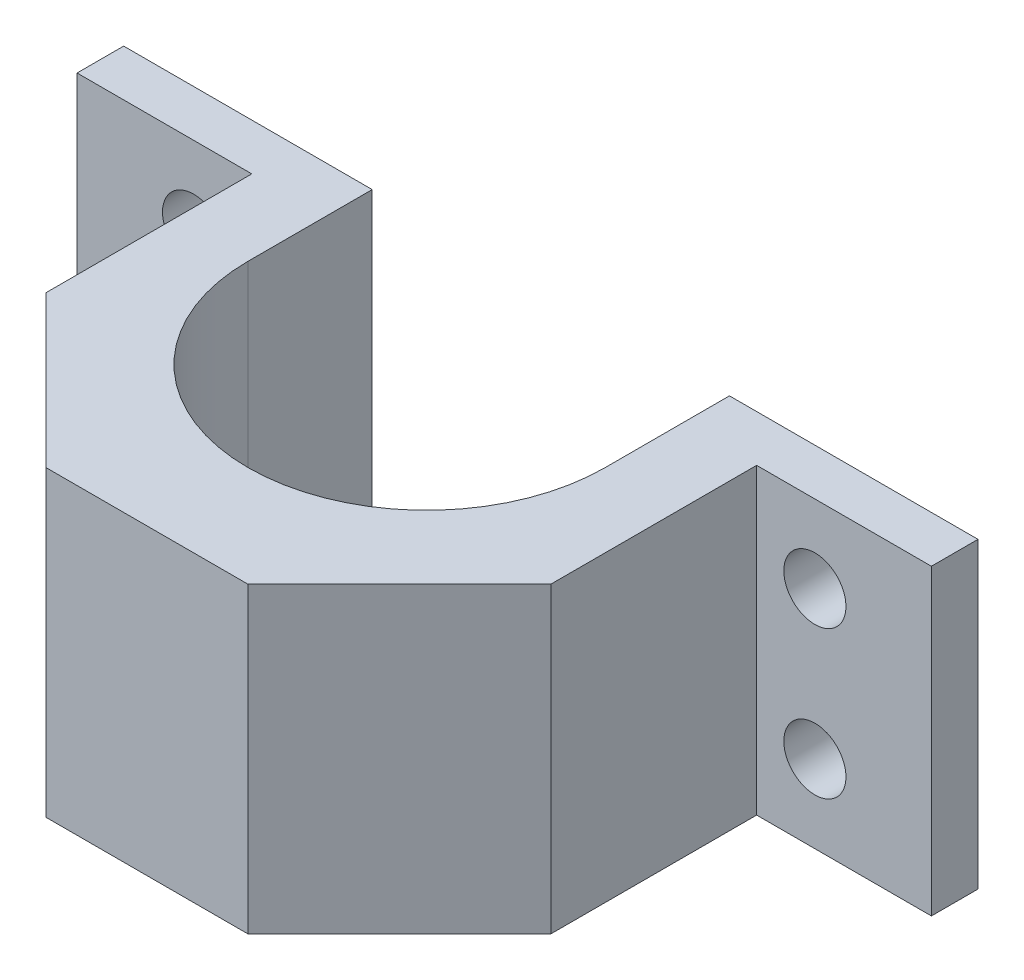
from build123d import *

# Parameters (mm, degrees)
BOSS_EXTRUDE1_DEPTH = 39
SKETCH2_R           = 4
CUT_EXTRUDE1_DEPTH  = 53


with BuildPart() as part:
    # Sketch1 → Boss-Extrude1 (new body)
    with BuildSketch(Plane(origin=(0, 0, 0), x_dir=(1, 0, 0), z_dir=(0, 1, 0))):
        with BuildLine():
            Line((-23, 0), (-23, 10))
            Line((-23, 10), (-23, 16))
            Line((-23, 16), (-55, 16))
            Line((-55, 16), (-55, 10))
            Line((-55, 10), (-32.5, 10))
            Line((-32.5, 10), (-32.5, -16.5))
            Line((-32.5, -16.5), (-13, -36))
            Line((-13, -36), (13, -36))
            Line((13, -36), (32.5, -16.5))
            Line((32.5, -16.5), (32.5, 10))
            Line((32.5, 10), (55, 10))
            Line((55, 10), (55, 16))
            Line((55, 16), (23, 16))
            Line((23, 16), (23, 10))
            Line((23, 10), (23, 0))
            ThreePointArc((23, 0), (0, -23), (-23, 0))
        make_face()
    extrude(amount=BOSS_EXTRUDE1_DEPTH)

    # Sketch2 → Cut-Extrude1 (cut, through all)
    with BuildSketch(Plane(origin=(0, 0, -16), x_dir=(-1, 0, 0), z_dir=(0, 0, -1))):
        with Locations((-40, 29)):
            Circle(SKETCH2_R)
        with Locations((-40, 10)):
            Circle(SKETCH2_R)
        with Locations((40, 29)):
            Circle(SKETCH2_R)
        with Locations((40, 10)):
            Circle(SKETCH2_R)
    extrude(amount=-CUT_EXTRUDE1_DEPTH, mode=Mode.SUBTRACT)


solid = part.part
